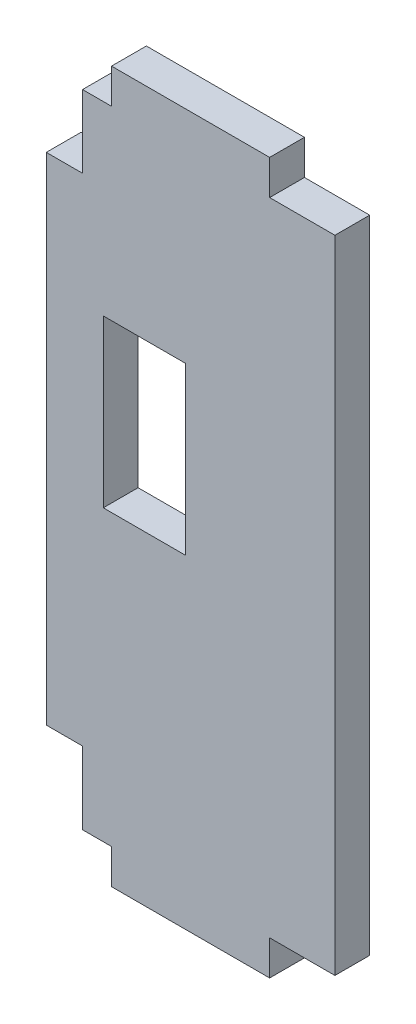
from build123d import *

# Parameters (mm, degrees)
SKETCH1_W           = 7.1882
SKETCH1_H           = 14.5542
BOSS_EXTRUDE1_DEPTH = 3.048


with BuildPart() as part:
    # Sketch1 → Boss-Extrude1 (new body)
    with BuildSketch(Plane.XY):
        Polygon((-17.3482, -0.5588), (-17.3482, -6.9088), (-20.5232, -6.9088), (-20.5232, -50.3428), (-17.3482, -50.3428), (-17.3482, -56.6928), (-14.8082, -56.6928), (-14.8082, -59.7408), (-0.9652, -59.7408), (-0.9652, -56.6928), (4.7498, -56.6928), (4.7498, -0.5588), (-0.9652, -0.5588), (-0.9652, 2.4892), (-14.8082, 2.4892), (-14.8082, -0.5588), align=None)
        with Locations((-11.938, -24.0919)):
            Rectangle(SKETCH1_W, SKETCH1_H, mode=Mode.SUBTRACT)
    extrude(amount=BOSS_EXTRUDE1_DEPTH)


solid = part.part
